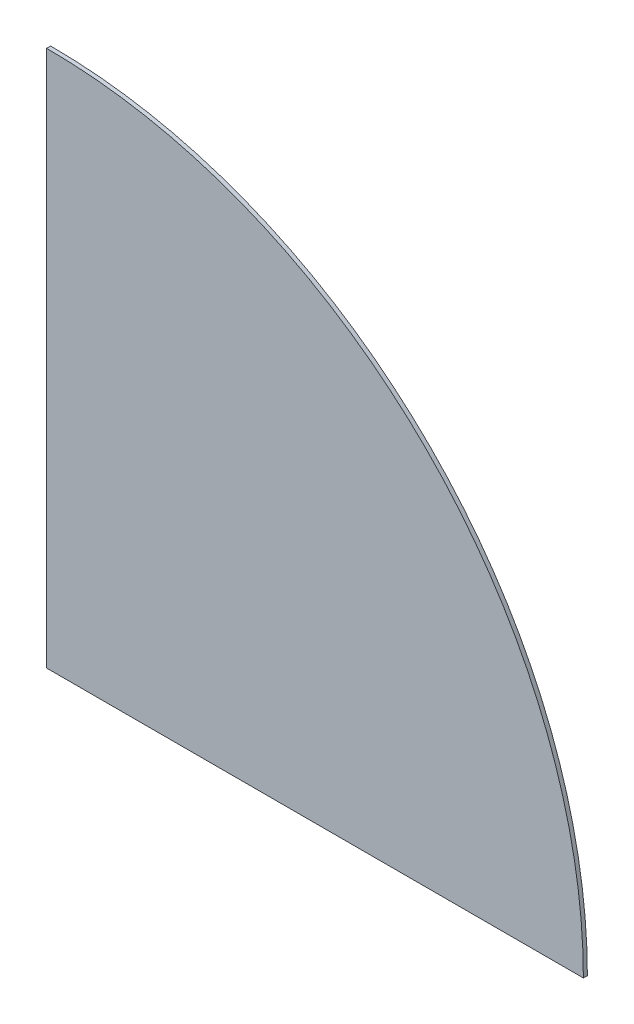
from build123d import *

# Parameters (mm, degrees)
BOSS_EXTRUDE1_DEPTH = 1


with BuildPart() as part:
    # Sketch1 → Boss-Extrude1 (new body)
    with BuildSketch(Plane.XY):
        with BuildLine():
            Line((-31, -334), (-165.408360025, -334))
            Line((-165.408360025, -334), (-165.408360025, -199.591639975))
            ThreePointArc((-165.408360025, -199.591639975), (-70.367297203, -238.958937178), (-31, -334))
        make_face()
    extrude(amount=BOSS_EXTRUDE1_DEPTH)


solid = part.part
